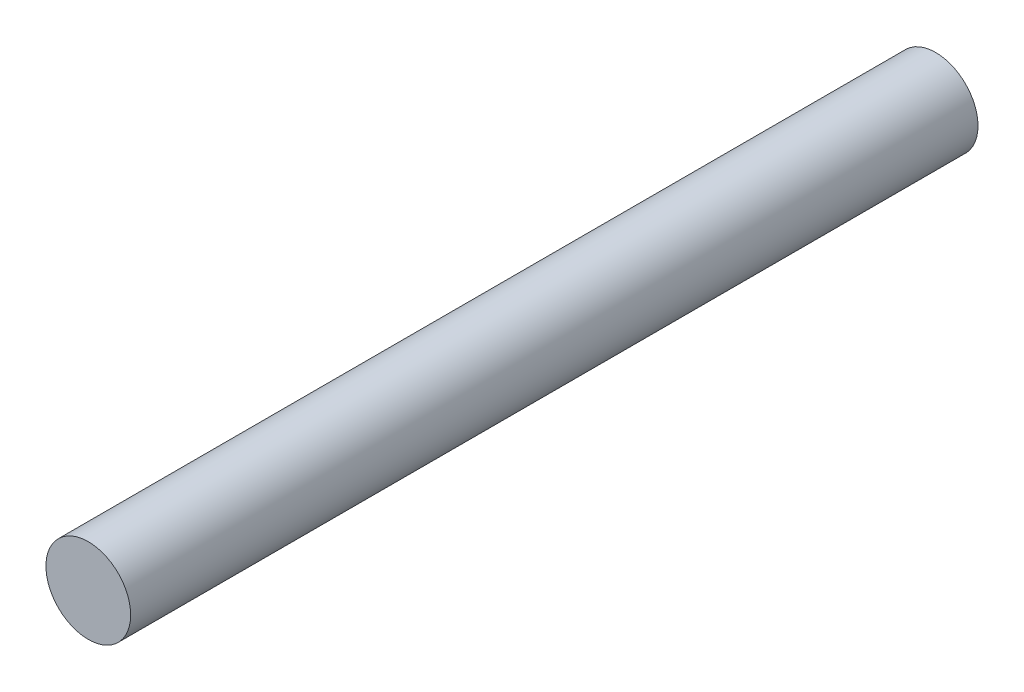
from build123d import *

# Parameters (mm, degrees)
SKETCH1_R           = 0.15
BOSS_EXTRUDE1_DEPTH = 3


with BuildPart() as part:
    # Sketch1 → Boss-Extrude1 (new body)
    with BuildSketch(Plane.XY):
        Circle(SKETCH1_R)
    extrude(amount=BOSS_EXTRUDE1_DEPTH)


solid = part.part
